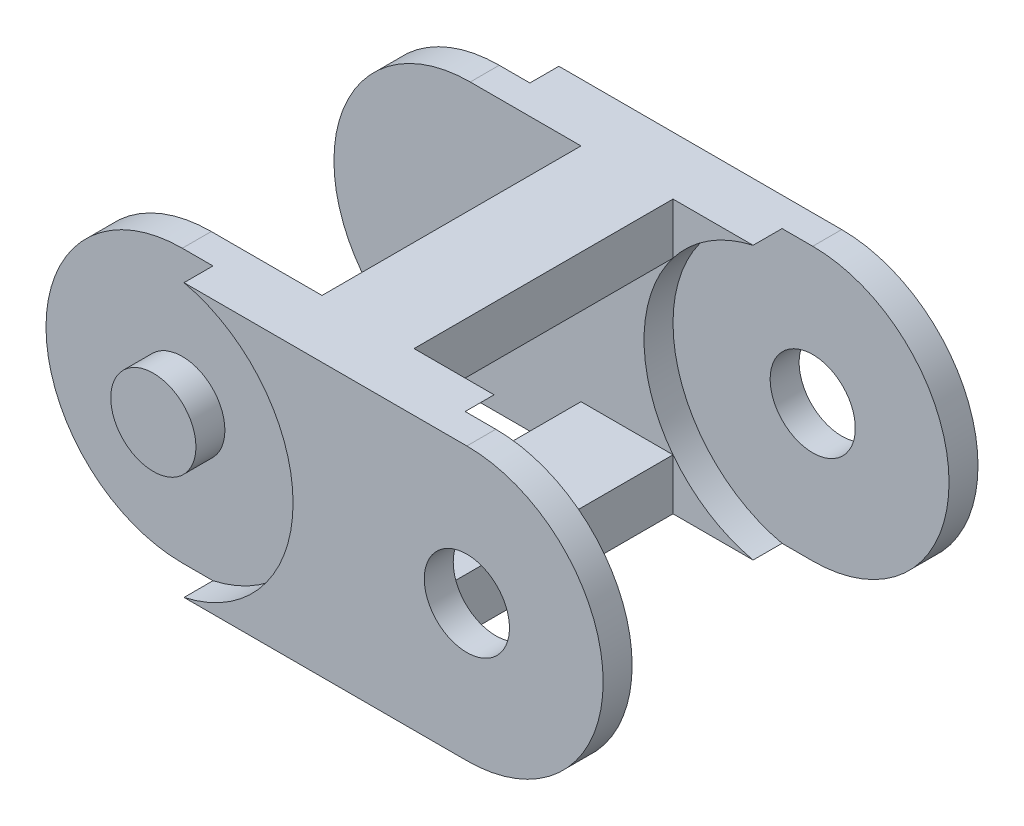
from build123d import *

# Parameters (mm, degrees)
BOSS_EXTRUDE1_DEPTH = 8.5
SKETCH2_R           = 20.5
CUT_EXTRUDE1_DEPTH  = 4.25
SKETCH3_R           = 20.5
CUT_EXTRUDE2_DEPTH  = 4.25
SKETCH4_R           = 6.25
CUT_EXTRUDE3_DEPTH  = 5.25
SKETCH5_R           = 6.25
BOSS_EXTRUDE2_DEPTH = 4.25
SKETCH6_W           = 13.503846382
SKETCH6_H           = 7.5
BOSS_EXTRUDE3_DEPTH = 38


with BuildPart() as part:
    # Sketch1 → Boss-Extrude1 (new body)
    with BuildSketch(Plane.XY):
        with BuildLine():
            Line((-23, 20), (23, 20))
            ThreePointArc((23, 20), (43, 0), (23, -20))
            Line((23, -20), (-23, -20))
            ThreePointArc((-23, -20), (-43, 0), (-23, 20))
        make_face()
    extrude(amount=BOSS_EXTRUDE1_DEPTH)

    # Sketch2 → Cut-Extrude1 (cut)
    with BuildSketch(Plane(origin=(0, 0, 0), x_dir=(-1, 0, 0), z_dir=(0, 0, -1))):
        with Locations((-23, 0)):
            Circle(SKETCH2_R)
    extrude(amount=-CUT_EXTRUDE1_DEPTH, mode=Mode.SUBTRACT)

    # Sketch3 → Cut-Extrude2 (cut)
    with BuildSketch(Plane.XY.offset(8.5)):
        with Locations((-23, 0)):
            Circle(SKETCH3_R)
    extrude(amount=-CUT_EXTRUDE2_DEPTH, mode=Mode.SUBTRACT)

    # Sketch4 → Cut-Extrude3 (cut, through all)
    with BuildSketch(Plane(origin=(0, 0, 4.25), x_dir=(-1, 0, 0), z_dir=(0, 0, -1))):
        with Locations((-23, 0)):
            Circle(SKETCH4_R)
    extrude(amount=-CUT_EXTRUDE3_DEPTH, mode=Mode.SUBTRACT)

    # Sketch5 → Boss-Extrude2 (add)
    with BuildSketch(Plane.XY.offset(4.25)):
        with Locations((-23, 0)):
            Circle(SKETCH5_R)
    extrude(amount=BOSS_EXTRUDE2_DEPTH)

    # Sketch6 → Boss-Extrude3 (add)
    with BuildSketch(Plane(origin=(0, 0, 0), x_dir=(-1, 0, 0), z_dir=(0, 0, -1))):
        with Locations((0, 16.25)):
            Rectangle(SKETCH6_W, SKETCH6_H)
    boss_extrude3 = extrude(amount=BOSS_EXTRUDE3_DEPTH)

    # Mirror1: Boss-Extrude3 across plane
    add(boss_extrude3.mirror(Plane.ZX))

    # Зеркальное отражение1: part across plane


with BuildPart() as part_1:
    add(part.part)
    add(part.part.mirror(Plane.XY.offset(-19)))


solid = part_1.part
